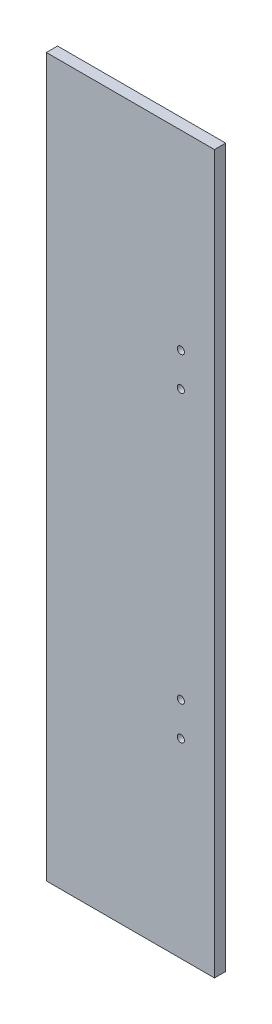
from build123d import *

# Parameters (mm, degrees)
SKETCH1_W           = 75
SKETCH1_H           = 320
BOSS_EXTRUDE1_DEPTH = 5
CUT_EXTRUDE1_REACH  = 7
SKETCH2_R           = 1.6


with BuildPart() as part:
    # Sketch1 → Boss-Extrude1 (new body)
    with BuildSketch(Plane.XY):
        Rectangle(SKETCH1_W, SKETCH1_H)
    extrude(amount=BOSS_EXTRUDE1_DEPTH)

    # Sketch2 → Cut-Extrude1 (cut, up to next)
    with BuildSketch(Plane(origin=(0, 0, 0), x_dir=(-1, 0, 0), z_dir=(0, 0, -1)), mode=Mode.PRIVATE) as cut_extrude1_sk1:
        with Locations((-22.5, 75)):
            Circle(SKETCH2_R)
    cut_extrude1_tool1 = extrude(cut_extrude1_sk1.sketch, amount=-CUT_EXTRUDE1_REACH, mode=Mode.PRIVATE) & part.part
    add(cut_extrude1_tool1.solids().sort_by_distance((22.5, 75, 0))[0], mode=Mode.SUBTRACT)
    # Sketch2 → Cut-Extrude1 (cut, up to next)
    with BuildSketch(Plane(origin=(0, 0, 0), x_dir=(-1, 0, 0), z_dir=(0, 0, -1)), mode=Mode.PRIVATE) as cut_extrude1_sk2:
        with Locations((-22.5, 60)):
            Circle(SKETCH2_R)
    cut_extrude1_tool2 = extrude(cut_extrude1_sk2.sketch, amount=-CUT_EXTRUDE1_REACH, mode=Mode.PRIVATE) & part.part
    add(cut_extrude1_tool2.solids().sort_by_distance((22.5, 60, 0))[0], mode=Mode.SUBTRACT)
    # Sketch2 → Cut-Extrude1 (cut, up to next)
    with BuildSketch(Plane(origin=(0, 0, 0), x_dir=(-1, 0, 0), z_dir=(0, 0, -1)), mode=Mode.PRIVATE) as cut_extrude1_sk3:
        with Locations((-22.5, -60)):
            Circle(SKETCH2_R)
    cut_extrude1_tool3 = extrude(cut_extrude1_sk3.sketch, amount=-CUT_EXTRUDE1_REACH, mode=Mode.PRIVATE) & part.part
    add(cut_extrude1_tool3.solids().sort_by_distance((22.5, -60, 0))[0], mode=Mode.SUBTRACT)
    # Sketch2 → Cut-Extrude1 (cut, up to next)
    with BuildSketch(Plane(origin=(0, 0, 0), x_dir=(-1, 0, 0), z_dir=(0, 0, -1)), mode=Mode.PRIVATE) as cut_extrude1_sk4:
        with Locations((-22.5, -75)):
            Circle(SKETCH2_R)
    cut_extrude1_tool4 = extrude(cut_extrude1_sk4.sketch, amount=-CUT_EXTRUDE1_REACH, mode=Mode.PRIVATE) & part.part
    add(cut_extrude1_tool4.solids().sort_by_distance((22.5, -75, 0))[0], mode=Mode.SUBTRACT)


solid = part.part
